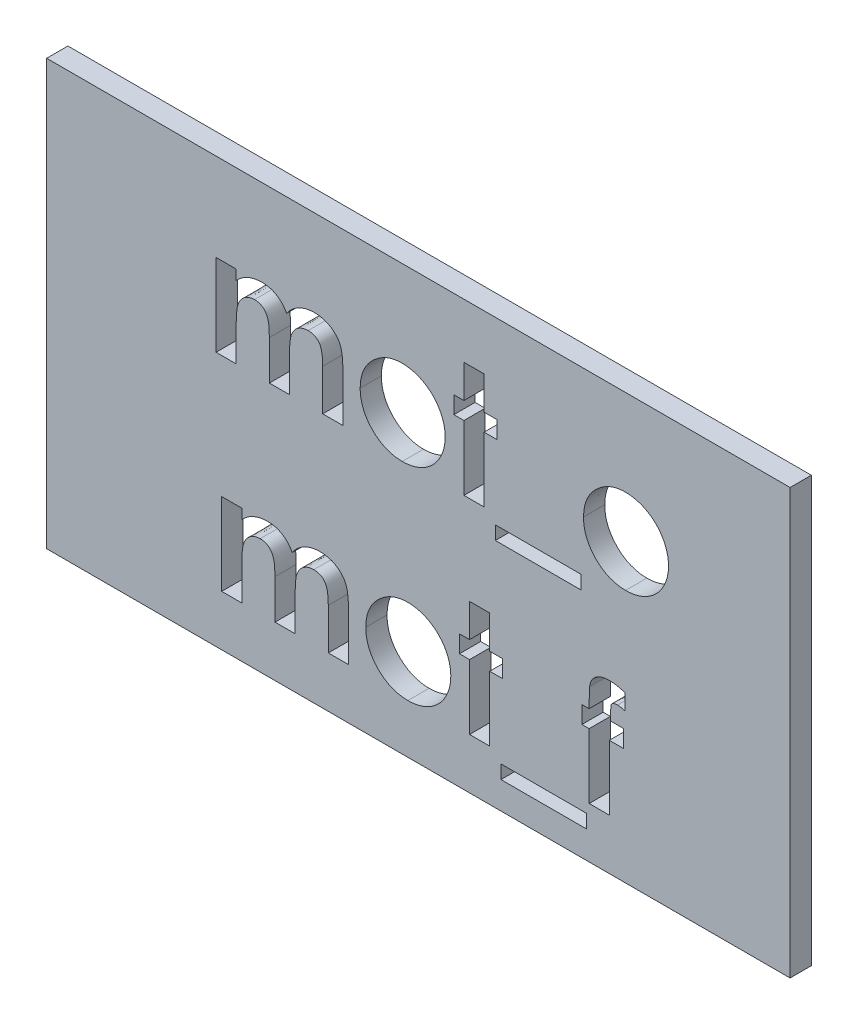
from build123d import *

# Parameters (mm, degrees)
ESQUISSE1_W             = 35
ESQUISSE1_H             = 20
BOSS_EXTRU_1_DEPTH      = 1
ESQUISSE2_R             = 1
BOSS_EXTRU_2_DEPTH      = 3
CHANFREIN1_SIZE         = 0.5
ESQUISSE3_W             = 3.731303419
ESQUISSE3_H             = 0.339209402
ENL_V_MAT_EXTRU_2_DEPTH = 1
ESQUISSE5_W             = 4.031303419
ESQUISSE5_H             = 0.639209402
ENL_V_MAT_EXTRU_3_DEPTH = 5


with BuildPart() as part:
    # Esquisse1 → Boss.-Extru.1 (new body)
    with BuildSketch(Plane.XY):
        with Locations((17.5, -10)):
            Rectangle(ESQUISSE1_W, ESQUISSE1_H)
    extrude(amount=BOSS_EXTRU_1_DEPTH)

    # Esquisse2 → Boss.-Extru.2 (add)
    with BuildSketch(Plane(origin=(0, 0, 0), x_dir=(-1, 0, 0), z_dir=(0, 0, -1))):
        with Locations(Location((-30, -5, 0), (0, 0, 180))):  # turned: the seam where the file's is
            Circle(ESQUISSE2_R)
        with Locations(Location((-5, -5, 0), (0, 0, 180))):  # turned: the seam where the file's is
            Circle(ESQUISSE2_R)
    extrude(amount=BOSS_EXTRU_2_DEPTH)

    # Chanfrein1
    chanfrein1_edges = [part.edges().sort_by_distance(p)[0] for p in [
        (29, -5, -3),
        (4, -5, -3),
    ]]
    chamfer(chanfrein1_edges, length=CHANFREIN1_SIZE)

    # Esquisse3 → Enlèv. mat.-Extru.2 (cut)
    with BuildSketch(Plane.XY.offset(1)):
        with BuildLine():
            Line((7.974893162, -4.133012821), (8.924679487, -4.133012821))
            Line((8.924679487, -4.133012821), (8.924679487, -4.59518563))
            add(Edge.make_bspline(
                [(8.924679487, -4.59518563), (8.9669255, -4.552547263), (9.050104428, -4.468595821), (9.187948183, -4.360668696), (9.331733176, -4.268377671), (9.483201855, -4.193662277), (9.641983734, -4.136611678), (9.807326268, -4.09480584), (9.980078727, -4.070141705), (10.097699802, -4.066846229), (10.157493657, -4.06517094)],
                knots=[0, 0, 0, 0, 1.041528618, 2.050684245, 3.032913108, 4.004406485, 4.976926473, 5.95771665, 6.961784757, 8, 8, 8, 8], degree=3))
            add(Edge.make_bspline(
                [(10.157493657, -4.06517094), (10.21736646, -4.067054206), (10.335224137, -4.070761355), (10.507177667, -4.104685241), (10.670076164, -4.159800091), (10.82212736, -4.238359539), (10.964430194, -4.335376374), (11.090680555, -4.45586279), (11.204321052, -4.595022486), (11.264895812, -4.700228713), (11.295965211, -4.754190037)],
                knots=[0, 0, 0, 0, 1.023965777, 2.015643508, 2.987309376, 3.958410333, 4.93654923, 5.924956801, 6.93568961, 8, 8, 8, 8], degree=3))
            add(Edge.make_bspline(
                [(11.295965211, -4.754190037), (11.335986612, -4.700081917), (11.414537392, -4.593882862), (11.553775804, -4.455227954), (11.704334069, -4.33536381), (11.869125143, -4.237643293), (12.043772747, -4.160068241), (12.227512644, -4.104890023), (12.418678987, -4.070818051), (12.548778175, -4.067068949), (12.61464176, -4.06517094)],
                knots=[0, 0, 0, 0, 1.041189987, 2.043563759, 3.033412161, 4.015238574, 5.00275396, 5.986226558, 6.980513695, 8, 8, 8, 8], degree=3))
            add(Edge.make_bspline(
                [(12.61464176, -4.06517094), (12.682671023, -4.067141729), (12.815151688, -4.070979658), (13.007135195, -4.108738156), (13.186950982, -4.167080701), (13.350625169, -4.251983383), (13.498624572, -4.352553973), (13.624737916, -4.471382321), (13.729400469, -4.604321999), (13.797549213, -4.728455222), (13.841605545, -4.838203205), (13.868207149, -4.933704514), (13.89308788, -5.040343805), (13.910962195, -5.159554459), (13.927647079, -5.290215988), (13.937333311, -5.433197075), (13.943917143, -5.588016049), (13.944616429, -5.695134454), (13.944978632, -5.750617655)],
                knots=[0, 0, 0, 0, 1.321991808, 2.574456155, 3.791773975, 4.987670122, 6.148905103, 7.262530793, 8.344737981, 9.427709016, 10.004683293, 10.642050061, 11.354108788, 12.133887687, 12.985666279, 13.916212488, 14.92067847, 16, 16, 16, 16], degree=3))
            Line((13.944978632, -5.750617655), (13.944978632, -8))
            Line((13.944978632, -8), (12.995192308, -8))
            Line((12.995192308, -8), (12.995192308, -6.058026175))
            add(Edge.make_bspline(
                [(12.995192308, -6.058026175), (12.99440179, -6.006081985), (12.992884464, -5.906379806), (12.986433725, -5.763376066), (12.971994212, -5.633684014), (12.955069252, -5.516585277), (12.930849308, -5.412700728), (12.901317484, -5.321779938), (12.867060748, -5.243692031), (12.825696772, -5.178445146), (12.779369069, -5.123496962), (12.727836184, -5.076395486), (12.671635424, -5.036208607), (12.610257247, -5.001955004), (12.542093703, -4.978788614), (12.469445885, -4.960611438), (12.391745302, -4.948232651), (12.338023137, -4.947494664), (12.310413328, -4.947115385)],
                knots=[0, 0, 0, 0, 1.669139205, 3.203761885, 4.596586177, 5.860166715, 7.002923539, 8.018877315, 8.928339525, 9.734594377, 10.491888885, 11.231098709, 11.971440889, 12.708030942, 13.480072485, 14.275788656, 15.113863979, 16, 16, 16, 16], degree=3))
            add(Edge.make_bspline(
                [(12.310413328, -4.947115385), (12.267867003, -4.948586321), (12.184378307, -4.951472742), (12.062718261, -4.979055723), (11.948235262, -5.024150945), (11.841358208, -5.085499), (11.744386859, -5.162121562), (11.659561475, -5.253003227), (11.589507538, -5.358667753), (11.541014495, -5.456703237), (11.510712435, -5.545347015), (11.489337085, -5.621263291), (11.47267585, -5.707113371), (11.459634981, -5.802027791), (11.44712379, -5.906543112), (11.440985869, -6.02052717), (11.434704904, -6.143821616), (11.434786669, -6.229033939), (11.43482906, -6.273212139)],
                knots=[0, 0, 0, 0, 1.129913425, 2.217230253, 3.297175357, 4.391411011, 5.481605898, 6.571841268, 7.681894157, 8.841607612, 9.468549532, 10.170608623, 10.93710061, 11.791434153, 12.717934886, 13.734733707, 14.825576123, 16, 16, 16, 16], degree=3))
            Line((11.43482906, -6.273212139), (11.43482906, -8))
            Line((11.43482906, -8), (10.485042735, -8))
            Line((10.485042735, -8), (10.485042735, -6.146008614))
            add(Edge.make_bspline(
                [(10.485042735, -6.146008614), (10.484962991, -6.104662165), (10.484809588, -6.02512499), (10.480198623, -5.910271787), (10.474092803, -5.804220605), (10.465533155, -5.706675648), (10.455661286, -5.617758237), (10.441413905, -5.537954814), (10.426445717, -5.466825637), (10.400782555, -5.386025014), (10.36461986, -5.296484401), (10.310592266, -5.201531568), (10.245265525, -5.122030947), (10.170290768, -5.057363855), (10.085566074, -5.00809272), (9.993237786, -4.971441119), (9.891542951, -4.95165771), (9.821543025, -4.948661445), (9.785423344, -4.947115385)],
                knots=[0, 0, 0, 0, 1.256487322, 2.417074606, 3.49288742, 4.484586665, 5.393016842, 6.210437544, 6.947749329, 7.599905853, 8.784490193, 9.876739139, 10.906602197, 11.896672079, 12.869113195, 13.872201355, 14.902064413, 16, 16, 16, 16], degree=3))
            add(Edge.make_bspline(
                [(9.785423344, -4.947115385), (9.744611212, -4.948500619), (9.663782443, -4.951244088), (9.546042994, -4.980711182), (9.433473161, -5.024978991), (9.328549367, -5.088038137), (9.233038897, -5.166463861), (9.149062796, -5.259930578), (9.079377019, -5.36832742), (9.030668724, -5.469067075), (9.000808504, -5.559922392), (8.978858402, -5.637809906), (8.96281707, -5.725550598), (8.949433057, -5.822159294), (8.936995937, -5.927750032), (8.93083262, -6.042787158), (8.924557861, -6.167143162), (8.924637968, -6.253061473), (8.924679487, -6.297592815)],
                knots=[0, 0, 0, 0, 1.07893236, 2.136834559, 3.195274846, 4.273923004, 5.364443877, 6.458052972, 7.587287137, 8.767908, 9.410170275, 10.118584836, 10.909717261, 11.770069756, 12.702352573, 13.724628867, 14.820678298, 16, 16, 16, 16], degree=3))
            Line((8.924679487, -6.297592815), (8.924679487, -8))
            Line((8.924679487, -8), (7.974893162, -8))
            Line((7.974893162, -8), (7.974893162, -4.133012821))
        make_face()
        with BuildLine():
            add(Edge.make_bspline(
                [(16.73709602, -4.06517094), (16.782000084, -4.065970039), (16.870930478, -4.067552616), (17.003381189, -4.080726126), (17.133516357, -4.102219251), (17.26208398, -4.130049096), (17.387890189, -4.169042871), (17.511594821, -4.215809874), (17.634303953, -4.269503864), (17.75297197, -4.333418492), (17.868456158, -4.402739736), (17.977942041, -4.479206755), (18.080520414, -4.562218928), (18.178095482, -4.649851552), (18.266120088, -4.745919865), (18.350219477, -4.845794894), (18.425849964, -4.953054811), (18.495872901, -5.065085941), (18.558213818, -5.18124043), (18.612345439, -5.300710266), (18.659326596, -5.421843694), (18.696111901, -5.546116201), (18.726566743, -5.67188909), (18.745785913, -5.800703613), (18.75944941, -5.931236522), (18.760981521, -6.019122018), (18.761752137, -6.063326322)],
                knots=[0, 0, 0, 0, 1.022364134, 2.024744242, 3.027414945, 4.024939316, 5.017584196, 6.023349371, 7.035562955, 8.064994934, 9.090267829, 10.101425541, 11.102933353, 12.093946398, 13.084502048, 14.067315274, 15.065326281, 16.070028806, 17.074376865, 18.064572984, 19.055292013, 20.030201733, 21.013838017, 21.999348303, 22.993720005, 24, 24, 24, 24], degree=3))
            add(Edge.make_bspline(
                [(18.761752137, -6.063326322), (18.76093888, -6.107875973), (18.759321941, -6.196450777), (18.746280242, -6.328211509), (18.724704848, -6.457631787), (18.696768191, -6.585474047), (18.657920342, -6.710102427), (18.612530776, -6.833353996), (18.556813299, -6.953548791), (18.495213523, -7.071998023), (18.424740368, -7.185216092), (18.349175348, -7.293550495), (18.265428208, -7.394159111), (18.178108263, -7.490162093), (18.083073731, -7.57831305), (17.98184154, -7.660043319), (17.875288079, -7.736352088), (17.762647117, -7.805449009), (17.645361396, -7.866162011), (17.525408918, -7.920899736), (17.402088268, -7.9664728), (17.275654665, -8.003636379), (17.14603143, -8.032411209), (17.013504738, -8.051958292), (16.878360004, -8.065553064), (16.787304803, -8.06707403), (16.741336138, -8.06784188)],
                knots=[0, 0, 0, 0, 1.012026251, 2.012137606, 3.004615893, 3.992048833, 4.982446996, 5.968083444, 6.973977695, 7.990229942, 8.999482246, 10.001782172, 10.988562221, 11.971415814, 12.948383116, 13.930088534, 14.925840678, 15.924049238, 16.929462851, 17.924729459, 18.917889337, 19.913673841, 20.916777188, 21.931792057, 22.95587778, 24, 24, 24, 24], degree=3))
            add(Edge.make_bspline(
                [(16.741336138, -8.06784188), (16.674120576, -8.065868971), (16.54163768, -8.061980337), (16.346521696, -8.03534421), (16.159079644, -7.989496451), (15.979006091, -7.925585687), (15.806067115, -7.843686424), (15.641771989, -7.742323649), (15.484486426, -7.623492905), (15.33693473, -7.488198559), (15.201757387, -7.339768411), (15.083663714, -7.181320132), (14.98339263, -7.015228595), (14.901034346, -6.841304401), (14.837470546, -6.659309053), (14.791566637, -6.469786652), (14.764897944, -6.272204479), (14.761042199, -6.137961452), (14.759081197, -6.069686498)],
                knots=[0, 0, 0, 0, 1.029999031, 2.030143771, 3.011211297, 3.982305373, 4.953580601, 5.938004764, 6.935448627, 7.970290061, 9.001484052, 10.007591832, 10.993831261, 11.969999897, 12.951306496, 13.942897864, 14.953773953, 16, 16, 16, 16], degree=3))
            add(Edge.make_bspline(
                [(14.759081197, -6.069686498), (14.761110585, -5.996783815), (14.765099306, -5.85349505), (14.796771511, -5.643573745), (14.847348605, -5.442584044), (14.919948838, -5.251088178), (15.012689251, -5.068732961), (15.125904276, -4.895902998), (15.260153431, -4.732559142), (15.362961401, -4.633763179), (15.415239383, -4.583525307)],
                knots=[0, 0, 0, 0, 1.043912699, 2.05178951, 3.033892, 4.007821512, 4.978932272, 5.95884105, 6.962068106, 8, 8, 8, 8], degree=3))
            add(Edge.make_bspline(
                [(15.415239383, -4.583525307), (15.463209657, -4.541883762), (15.557845078, -4.459733615), (15.711596489, -4.35553962), (15.869020585, -4.265547797), (16.032004161, -4.19155778), (16.201001573, -4.135770502), (16.375146805, -4.095162354), (16.554403646, -4.07021964), (16.675889089, -4.066862392), (16.73709602, -4.06517094)],
                knots=[0, 0, 0, 0, 1.048115528, 2.067714963, 3.060638214, 4.039924844, 5.017819947, 5.994373833, 6.98952318, 8, 8, 8, 8], degree=3))
        make_face()
        Polygon((19.643696581, -2.572649573), (20.593482906, -2.572649573), (20.593482906, -4.133012821), (21.204059829, -4.133012821), (21.204059829, -4.947115385), (20.593482906, -4.947115385), (20.593482906, -8), (19.643696581, -8), (19.643696581, -4.947115385), (19.168803419, -4.947115385), (19.168803419, -4.133012821), (19.643696581, -4.133012821), align=None)
        with Locations((23.137553419, -8.780181624)):
            Rectangle(ESQUISSE3_W, ESQUISSE3_H)
        with BuildLine():
            add(Edge.make_bspline(
                [(27.252587473, -4.06517094), (27.297491537, -4.065970039), (27.386421931, -4.067552616), (27.518872642, -4.080726126), (27.64900781, -4.102219251), (27.777575433, -4.130049096), (27.903381642, -4.169042871), (28.027086274, -4.215809874), (28.149795406, -4.269503864), (28.268463423, -4.333418492), (28.383947611, -4.402739736), (28.493433494, -4.479206755), (28.596011867, -4.562218928), (28.693586935, -4.649851552), (28.781611541, -4.745919865), (28.86571093, -4.845794894), (28.941341417, -4.953054811), (29.011364354, -5.065085941), (29.073705271, -5.18124043), (29.127836892, -5.300710266), (29.174818049, -5.421843694), (29.211603354, -5.546116201), (29.242058196, -5.67188909), (29.261277366, -5.800703613), (29.274940863, -5.931236522), (29.276472974, -6.019122018), (29.27724359, -6.063326322)],
                knots=[0, 0, 0, 0, 1.022364134, 2.024744242, 3.027414945, 4.024939316, 5.017584196, 6.023349371, 7.035562955, 8.064994934, 9.090267829, 10.101425541, 11.102933353, 12.093946398, 13.084502048, 14.067315274, 15.065326281, 16.070028806, 17.074376865, 18.064572984, 19.055292013, 20.030201733, 21.013838017, 21.999348303, 22.993720005, 24, 24, 24, 24], degree=3))
            add(Edge.make_bspline(
                [(29.27724359, -6.063326322), (29.276430333, -6.107875973), (29.274813394, -6.196450777), (29.261771695, -6.328211509), (29.240196301, -6.457631787), (29.212259644, -6.585474047), (29.173411795, -6.710102427), (29.128022229, -6.833353996), (29.072304752, -6.953548791), (29.010704976, -7.071998023), (28.940231821, -7.185216092), (28.864666801, -7.293550495), (28.780919661, -7.394159111), (28.693599716, -7.490162093), (28.598565184, -7.57831305), (28.497332993, -7.660043319), (28.390779532, -7.736352088), (28.27813857, -7.805449009), (28.160852849, -7.866162011), (28.040900371, -7.920899736), (27.917579721, -7.9664728), (27.791146118, -8.003636379), (27.661522883, -8.032411209), (27.528996191, -8.051958292), (27.393851457, -8.065553064), (27.302796256, -8.06707403), (27.256827591, -8.06784188)],
                knots=[0, 0, 0, 0, 1.012026251, 2.012137606, 3.004615893, 3.992048833, 4.982446996, 5.968083444, 6.973977695, 7.990229942, 8.999482246, 10.001782172, 10.988562221, 11.971415814, 12.948383116, 13.930088534, 14.925840678, 15.924049238, 16.929462851, 17.924729459, 18.917889337, 19.913673841, 20.916777188, 21.931792057, 22.95587778, 24, 24, 24, 24], degree=3))
            add(Edge.make_bspline(
                [(27.256827591, -8.06784188), (27.189612029, -8.065868971), (27.057129133, -8.061980337), (26.862013149, -8.03534421), (26.674571097, -7.989496451), (26.494497544, -7.925585687), (26.321558567, -7.843686424), (26.157263442, -7.742323649), (25.999977879, -7.623492905), (25.852426183, -7.488198559), (25.71724884, -7.339768411), (25.599155167, -7.181320132), (25.498884083, -7.015228595), (25.416525799, -6.841304401), (25.352961999, -6.659309053), (25.30705809, -6.469786652), (25.280389397, -6.272204479), (25.276533652, -6.137961452), (25.27457265, -6.069686498)],
                knots=[0, 0, 0, 0, 1.029999031, 2.030143771, 3.011211297, 3.982305373, 4.953580601, 5.938004764, 6.935448627, 7.970290061, 9.001484052, 10.007591832, 10.993831261, 11.969999897, 12.951306496, 13.942897864, 14.953773953, 16, 16, 16, 16], degree=3))
            add(Edge.make_bspline(
                [(25.27457265, -6.069686498), (25.276602038, -5.996783815), (25.280590759, -5.85349505), (25.312262964, -5.643573745), (25.362840058, -5.442584044), (25.435440291, -5.251088178), (25.528180704, -5.068732961), (25.641395729, -4.895902998), (25.775644884, -4.732559142), (25.878452854, -4.633763179), (25.930730836, -4.583525307)],
                knots=[0, 0, 0, 0, 1.043912699, 2.05178951, 3.033892, 4.007821512, 4.978932272, 5.95884105, 6.962068106, 8, 8, 8, 8], degree=3))
            add(Edge.make_bspline(
                [(25.930730836, -4.583525307), (25.97870111, -4.541883762), (26.073336531, -4.459733615), (26.227087942, -4.35553962), (26.384512038, -4.265547797), (26.547495614, -4.19155778), (26.716493026, -4.135770502), (26.890638258, -4.095162354), (27.069895099, -4.07021964), (27.191380542, -4.066862392), (27.252587473, -4.06517094)],
                knots=[0, 0, 0, 0, 1.048115528, 2.067714963, 3.060638214, 4.039924844, 5.017819947, 5.994373833, 6.98952318, 8, 8, 8, 8], degree=3))
        make_face()
        with BuildLine():
            Line((8.239583333, -13.748931624), (9.189369658, -13.748931624))
            Line((9.189369658, -13.748931624), (9.189369658, -14.211104434))
            add(Edge.make_bspline(
                [(9.189369658, -14.211104434), (9.231615671, -14.168466066), (9.314794599, -14.084514625), (9.452638353, -13.9765875), (9.596423347, -13.884296474), (9.747892026, -13.80958108), (9.906673905, -13.752530481), (10.072016439, -13.710724643), (10.244768897, -13.686060508), (10.362389973, -13.682765032), (10.422183827, -13.681089744)],
                knots=[0, 0, 0, 0, 1.041528618, 2.050684245, 3.032913108, 4.004406485, 4.976926473, 5.95771665, 6.961784757, 8, 8, 8, 8], degree=3))
            add(Edge.make_bspline(
                [(10.422183827, -13.681089744), (10.482056631, -13.68297301), (10.599914308, -13.686680159), (10.771867838, -13.720604044), (10.934766335, -13.775718895), (11.086817531, -13.854278343), (11.229120365, -13.951295177), (11.355370726, -14.071781594), (11.469011223, -14.21094129), (11.529585983, -14.316147516), (11.560655382, -14.370108841)],
                knots=[0, 0, 0, 0, 1.023965777, 2.015643508, 2.987309376, 3.958410333, 4.93654923, 5.924956801, 6.93568961, 8, 8, 8, 8], degree=3))
            add(Edge.make_bspline(
                [(11.560655382, -14.370108841), (11.600676783, -14.316000721), (11.679227563, -14.209801665), (11.818465975, -14.071146757), (11.96902424, -13.951282614), (12.133815314, -13.853562096), (12.308462918, -13.775987045), (12.492202815, -13.720808826), (12.683369158, -13.686736855), (12.813468345, -13.682987752), (12.879331931, -13.681089744)],
                knots=[0, 0, 0, 0, 1.041189987, 2.043563759, 3.033412161, 4.015238574, 5.00275396, 5.986226558, 6.980513695, 8, 8, 8, 8], degree=3))
            add(Edge.make_bspline(
                [(12.879331931, -13.681089744), (12.947361194, -13.683060533), (13.079841859, -13.686898461), (13.271825366, -13.724656959), (13.451641153, -13.782999504), (13.61531534, -13.867902186), (13.763314743, -13.968472776), (13.889428087, -14.087301124), (13.99409064, -14.220240803), (14.062239384, -14.344374025), (14.106295716, -14.454122008), (14.13289732, -14.549623318), (14.157778051, -14.656262608), (14.175652366, -14.775473262), (14.19233725, -14.906134791), (14.202023482, -15.049115878), (14.208607314, -15.203934852), (14.2093066, -15.311053257), (14.209668803, -15.366536458)],
                knots=[0, 0, 0, 0, 1.321991808, 2.574456155, 3.791773975, 4.987670122, 6.148905103, 7.262530793, 8.344737981, 9.427709016, 10.004683293, 10.642050061, 11.354108788, 12.133887687, 12.985666279, 13.916212488, 14.92067847, 16, 16, 16, 16], degree=3))
            Line((14.209668803, -15.366536458), (14.209668803, -17.615918803))
            Line((14.209668803, -17.615918803), (13.259882479, -17.615918803))
            Line((13.259882479, -17.615918803), (13.259882479, -15.673944979))
            add(Edge.make_bspline(
                [(13.259882479, -15.673944979), (13.259091961, -15.622000789), (13.257574635, -15.52229861), (13.251123896, -15.379294869), (13.236684383, -15.249602817), (13.219759423, -15.132504081), (13.195539479, -15.028619531), (13.166007655, -14.937698741), (13.131750919, -14.859610835), (13.090386942, -14.794363949), (13.04405924, -14.739415765), (12.992526355, -14.69231429), (12.936325595, -14.652127411), (12.874947418, -14.617873808), (12.806783874, -14.594707417), (12.734136056, -14.576530241), (12.656435473, -14.564151454), (12.602713308, -14.563413467), (12.575103499, -14.563034188)],
                knots=[0, 0, 0, 0, 1.669139205, 3.203761885, 4.596586177, 5.860166715, 7.002923539, 8.018877315, 8.928339525, 9.734594377, 10.491888885, 11.231098709, 11.971440889, 12.708030942, 13.480072485, 14.275788656, 15.113863979, 16, 16, 16, 16], degree=3))
            add(Edge.make_bspline(
                [(12.575103499, -14.563034188), (12.532557174, -14.564505125), (12.449068478, -14.567391545), (12.327408432, -14.594974527), (12.212925432, -14.640069748), (12.106048379, -14.701417804), (12.00907703, -14.778040366), (11.924251646, -14.86892203), (11.854197709, -14.974586556), (11.805704666, -15.072622041), (11.775402606, -15.161265818), (11.754027256, -15.237182095), (11.737366021, -15.323032174), (11.724325152, -15.417946594), (11.71181396, -15.522461915), (11.70567604, -15.636445974), (11.699395075, -15.759740419), (11.69947684, -15.844952743), (11.699519231, -15.889130943)],
                knots=[0, 0, 0, 0, 1.129913425, 2.217230253, 3.297175357, 4.391411011, 5.481605898, 6.571841268, 7.681894157, 8.841607612, 9.468549532, 10.170608623, 10.93710061, 11.791434153, 12.717934886, 13.734733707, 14.825576123, 16, 16, 16, 16], degree=3))
            Line((11.699519231, -15.889130943), (11.699519231, -17.615918803))
            Line((11.699519231, -17.615918803), (10.749732906, -17.615918803))
            Line((10.749732906, -17.615918803), (10.749732906, -15.761927417))
            add(Edge.make_bspline(
                [(10.749732906, -15.761927417), (10.749653162, -15.720580968), (10.749499759, -15.641043793), (10.744888794, -15.526190591), (10.738782974, -15.420139408), (10.730223326, -15.322594451), (10.720351457, -15.233677041), (10.706104076, -15.153873618), (10.691135888, -15.08274444), (10.665472726, -15.001943817), (10.629310031, -14.912403205), (10.575282437, -14.817450371), (10.509955696, -14.73794975), (10.434980938, -14.673282658), (10.350256245, -14.624011523), (10.257927957, -14.587359922), (10.156233122, -14.567576513), (10.086233196, -14.564580249), (10.050113515, -14.563034188)],
                knots=[0, 0, 0, 0, 1.256487322, 2.417074606, 3.49288742, 4.484586665, 5.393016842, 6.210437544, 6.947749329, 7.599905853, 8.784490193, 9.876739139, 10.906602197, 11.896672079, 12.869113195, 13.872201355, 14.902064413, 16, 16, 16, 16], degree=3))
            add(Edge.make_bspline(
                [(10.050113515, -14.563034188), (10.009301383, -14.564419423), (9.928472614, -14.567162891), (9.810733165, -14.596629986), (9.698163332, -14.640897795), (9.593239538, -14.70395694), (9.497729067, -14.782382665), (9.413752967, -14.875849381), (9.34406719, -14.984246224), (9.295358895, -15.084985878), (9.265498675, -15.175841195), (9.243548573, -15.25372871), (9.227507241, -15.341469401), (9.214123228, -15.438078098), (9.201686108, -15.543668836), (9.195522791, -15.658705961), (9.189248032, -15.783061965), (9.189328139, -15.868980277), (9.189369658, -15.913511619)],
                knots=[0, 0, 0, 0, 1.07893236, 2.136834559, 3.195274846, 4.273923004, 5.364443877, 6.458052972, 7.587287137, 8.767908, 9.410170275, 10.118584836, 10.909717261, 11.770069756, 12.702352573, 13.724628867, 14.820678298, 16, 16, 16, 16], degree=3))
            Line((9.189369658, -15.913511619), (9.189369658, -17.615918803))
            Line((9.189369658, -17.615918803), (8.239583333, -17.615918803))
            Line((8.239583333, -17.615918803), (8.239583333, -13.748931624))
        make_face()
        with BuildLine():
            add(Edge.make_bspline(
                [(17.001786191, -13.681089744), (17.046690255, -13.681888842), (17.135620649, -13.683471419), (17.26807136, -13.696644929), (17.398206528, -13.718138054), (17.526774151, -13.745967899), (17.65258036, -13.784961674), (17.776284992, -13.831728678), (17.898994124, -13.885422667), (18.01766214, -13.949337296), (18.133146328, -14.018658539), (18.242632212, -14.095125559), (18.345210585, -14.178137732), (18.442785653, -14.265770355), (18.530810259, -14.361838669), (18.614909648, -14.461713697), (18.690540135, -14.568973615), (18.760563072, -14.681004745), (18.822903989, -14.797159234), (18.87703561, -14.91662907), (18.924016767, -15.037762497), (18.960802072, -15.162035004), (18.991256914, -15.287807893), (19.010476084, -15.416622416), (19.024139581, -15.547155325), (19.025671692, -15.635040821), (19.026442308, -15.679245126)],
                knots=[0, 0, 0, 0, 1.022364134, 2.024744242, 3.027414945, 4.024939316, 5.017584196, 6.023349371, 7.035562955, 8.064994934, 9.090267829, 10.101425541, 11.102933353, 12.093946398, 13.084502048, 14.067315274, 15.065326281, 16.070028806, 17.074376865, 18.064572984, 19.055292013, 20.030201733, 21.013838017, 21.999348303, 22.993720005, 24, 24, 24, 24], degree=3))
            add(Edge.make_bspline(
                [(19.026442308, -15.679245126), (19.025629051, -15.723794776), (19.024012112, -15.81236958), (19.010970413, -15.944130312), (18.989395019, -16.07355059), (18.961458362, -16.201392851), (18.922610513, -16.32602123), (18.877220947, -16.4492728), (18.82150347, -16.569467594), (18.759903694, -16.687916826), (18.689430539, -16.801134896), (18.613865519, -16.909469299), (18.530118379, -17.010077915), (18.442798434, -17.106080897), (18.347763902, -17.194231854), (18.24653171, -17.275962122), (18.13997825, -17.352270891), (18.027337288, -17.421367813), (17.910051567, -17.482080814), (17.790099089, -17.536818539), (17.666778439, -17.582391604), (17.540344836, -17.619555183), (17.410721601, -17.648330012), (17.278194909, -17.667877096), (17.143050175, -17.681471867), (17.051994974, -17.682992833), (17.006026309, -17.683760684)],
                knots=[0, 0, 0, 0, 1.012026251, 2.012137606, 3.004615893, 3.992048833, 4.982446996, 5.968083444, 6.973977695, 7.990229942, 8.999482246, 10.001782172, 10.988562221, 11.971415814, 12.948383116, 13.930088534, 14.925840678, 15.924049238, 16.929462851, 17.924729459, 18.917889337, 19.913673841, 20.916777188, 21.931792057, 22.95587778, 24, 24, 24, 24], degree=3))
            add(Edge.make_bspline(
                [(17.006026309, -17.683760684), (16.938810747, -17.681787774), (16.806327851, -17.67789914), (16.611211867, -17.651263013), (16.423769815, -17.605415255), (16.243696262, -17.54150449), (16.070757285, -17.459605227), (15.90646216, -17.358242452), (15.749176597, -17.239411708), (15.601624901, -17.104117363), (15.466447558, -16.955687214), (15.348353885, -16.797238935), (15.248082801, -16.631147399), (15.165724517, -16.457223205), (15.102160717, -16.275227856), (15.056256808, -16.085705455), (15.029588115, -15.888123283), (15.02573237, -15.753880255), (15.023771368, -15.685605302)],
                knots=[0, 0, 0, 0, 1.029999031, 2.030143771, 3.011211297, 3.982305373, 4.953580601, 5.938004764, 6.935448627, 7.970290061, 9.001484052, 10.007591832, 10.993831261, 11.969999897, 12.951306496, 13.942897864, 14.953773953, 16, 16, 16, 16], degree=3))
            add(Edge.make_bspline(
                [(15.023771368, -15.685605302), (15.025800756, -15.612702618), (15.029789477, -15.469413854), (15.061461682, -15.259492548), (15.112038776, -15.058502847), (15.184639009, -14.867006982), (15.277379422, -14.684651764), (15.390594447, -14.511821801), (15.524843602, -14.348477946), (15.627651572, -14.249681982), (15.679929554, -14.199444111)],
                knots=[0, 0, 0, 0, 1.043912699, 2.05178951, 3.033892, 4.007821512, 4.978932272, 5.95884105, 6.962068106, 8, 8, 8, 8], degree=3))
            add(Edge.make_bspline(
                [(15.679929554, -14.199444111), (15.727899828, -14.157802566), (15.822535249, -14.075652418), (15.97628666, -13.971458423), (16.133710756, -13.8814666), (16.296694332, -13.807476584), (16.465691744, -13.751689305), (16.639836976, -13.711081157), (16.819093817, -13.686138443), (16.94057926, -13.682781196), (17.001786191, -13.681089744)],
                knots=[0, 0, 0, 0, 1.048115528, 2.067714963, 3.060638214, 4.039924844, 5.017819947, 5.994373833, 6.98952318, 8, 8, 8, 8], degree=3))
        make_face()
        Polygon((19.908386752, -12.188568376), (20.858173077, -12.188568376), (20.858173077, -13.748931624), (21.46875, -13.748931624), (21.46875, -14.563034188), (20.858173077, -14.563034188), (20.858173077, -17.615918803), (19.908386752, -17.615918803), (19.908386752, -14.563034188), (19.43349359, -14.563034188), (19.43349359, -13.748931624), (19.908386752, -13.748931624), align=None)
        with Locations((23.40224359, -18.396100427)):
            Rectangle(ESQUISSE3_W, ESQUISSE3_H)
        with BuildLine():
            Line((25.200053419, -13.748931624), (25.539262821, -13.748931624))
            add(Edge.make_bspline(
                [(25.539262821, -13.748931624), (25.539489506, -13.687448699), (25.539918137, -13.571192847), (25.54244956, -13.406542218), (25.544156623, -13.261657317), (25.547205814, -13.13656043), (25.551497226, -13.031617987), (25.555896376, -12.946835723), (25.559191635, -12.881678712), (25.563837513, -12.845065074), (25.565763555, -12.829886151)],
                knots=[0, 0, 0, 0, 1.604323161, 3.033556972, 4.296844687, 5.385167547, 6.298701784, 7.037230881, 7.60086462, 8, 8, 8, 8], degree=3))
            add(Edge.make_bspline(
                [(25.565763555, -12.829886151), (25.574794999, -12.777809181), (25.59240034, -12.676293541), (25.650679704, -12.534801298), (25.735364318, -12.411545355), (25.825135208, -12.324544795), (25.908329808, -12.265151715), (25.978123165, -12.226359969), (26.054010722, -12.193103586), (26.136237671, -12.167026595), (26.224021979, -12.145725028), (26.318310992, -12.130917234), (26.418587407, -12.122756841), (26.487621281, -12.121414065), (26.522970085, -12.120726496)],
                knots=[0, 0, 0, 0, 1.43722947, 2.801646624, 4.13175475, 5.486897933, 6.18427957, 6.91287343, 7.658885333, 8.438447905, 9.260561323, 10.118602268, 11.036630026, 12, 12, 12, 12], degree=3))
            add(Edge.make_bspline(
                [(26.522970085, -12.120726496), (26.577130266, -12.122416646), (26.689935031, -12.125936889), (26.863250376, -12.154395886), (27.047125865, -12.197962004), (27.170918634, -12.238502881), (27.235309829, -12.259590345)],
                knots=[0, 0, 0, 0, 0.891275659, 1.856347963, 2.884972697, 4, 4, 4, 4], degree=3))
            Line((27.235309829, -12.259590345), (27.235309829, -12.998430823))
            add(Edge.make_bspline(
                [(27.235309829, -12.998430823), (27.200772657, -12.988881877), (27.13490255, -12.970669903), (27.040125901, -12.950452993), (26.954729267, -12.937969102), (26.901081175, -12.935830489), (26.875959869, -12.93482906)],
                knots=[0, 0, 0, 0, 1.174725213, 2.24046353, 3.176077791, 4, 4, 4, 4], degree=3))
            add(Edge.make_bspline(
                [(26.875959869, -12.93482906), (26.848312104, -12.935411685), (26.796504454, -12.936503435), (26.724691512, -12.950392621), (26.663204322, -12.972261763), (26.631311698, -12.997237907), (26.616252671, -13.009031116)],
                knots=[0, 0, 0, 0, 1.199997209, 2.248609783, 3.173030359, 4, 4, 4, 4], degree=3))
            add(Edge.make_bspline(
                [(26.616252671, -13.009031116), (26.607140082, -13.020671677), (26.587007397, -13.04638948), (26.568708077, -13.098868326), (26.559417716, -13.165196957), (26.557785369, -13.214283578), (26.556891026, -13.241177551)],
                knots=[0, 0, 0, 0, 0.721105823, 1.593158367, 2.681320256, 4, 4, 4, 4], degree=3))
            Line((26.556891026, -13.241177551), (26.553710937, -13.748931624))
            Line((26.553710937, -13.748931624), (27.167467949, -13.748931624))
            Line((27.167467949, -13.748931624), (27.167467949, -14.563034188))
            Line((27.167467949, -14.563034188), (26.489049145, -14.563034188))
            Line((26.489049145, -14.563034188), (26.489049145, -17.615918803))
            Line((26.489049145, -17.615918803), (25.539262821, -17.615918803))
            Line((25.539262821, -17.615918803), (25.539262821, -14.563034188))
            Line((25.539262821, -14.563034188), (25.200053419, -14.563034188))
            Line((25.200053419, -14.563034188), (25.200053419, -13.748931624))
        make_face()
    extrude(amount=-ENL_V_MAT_EXTRU_2_DEPTH, mode=Mode.SUBTRACT)

    # Esquisse5 → Enlèv. mat.-Extru.3 (cut, through all)
    with BuildSketch(Plane.XY.offset(1)):
        with Locations((23.137553419, -8.780181624)):
            Rectangle(ESQUISSE5_W, ESQUISSE5_H)
        with Locations((23.40224359, -18.396100427)):
            Rectangle(ESQUISSE5_W, ESQUISSE5_H)
    extrude(amount=-ENL_V_MAT_EXTRU_3_DEPTH, mode=Mode.SUBTRACT)


solid = part.part
